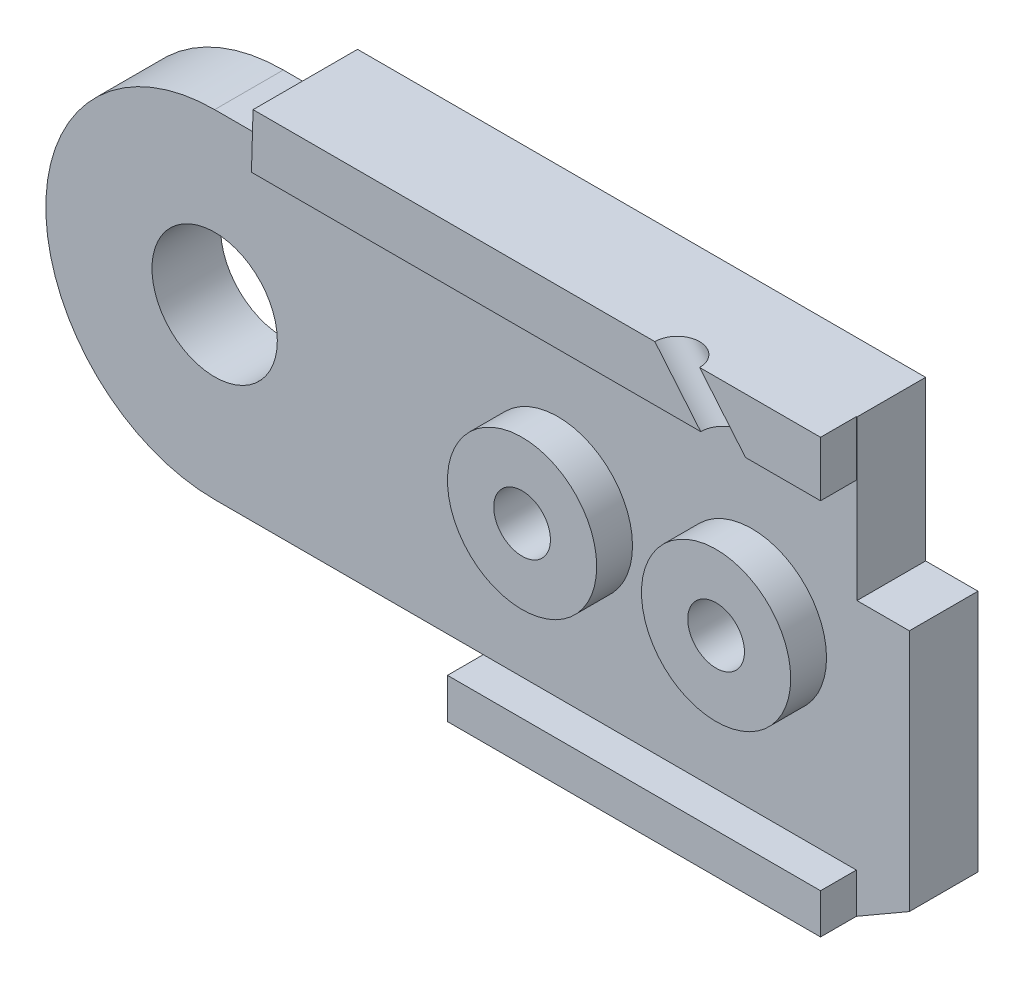
from build123d import *

# Parameters (mm, degrees)
BOSS_EXTRUDE1_DEPTH  = 2
BOSS_EXTRUDE6_DEPTH  = 2.5
CUT_EXTRUDE6_DEPTH   = 2.5
BOSS_EXTRUDE14_DEPTH = 2.3
SKETCH32_R           = 2.1
CUT_EXTRUDE7_DEPTH   = 2.3
SKETCH33_W           = 12.5
SKETCH33_H           = 1.343145751
BOSS_EXTRUDE15_DEPTH = 1.2
SKETCH35_W           = 5.479645997
SKETCH35_H           = 5.327993755
CUT_EXTRUDE8_DEPTH   = 2.4
SKETCH36_W           = 3.7
SKETCH36_H           = 1.827993755
CUT_EXTRUDE9_DEPTH   = 2.4
SKETCH37_R           = 3.9
BOSS_EXTRUDE16_DEPTH = 2.3
CUT_EXTRUDE10_DEPTH  = 5.3
SKETCH43_R           = 2.5
BOSS_EXTRUDE17_DEPTH = 1.2
SKETCH44_R           = 0.95
CUT_EXTRUDE11_DEPTH  = 9
SKETCH45_R           = 2
CUT_EXTRUDE12_DEPTH  = 2.5
SKETCH52_R           = 0.75
CUT_EXTRUDE13_DEPTH  = 10


with BuildPart() as part:
    # Sketch3 → Boss-Extrude1 (new body)
    with BuildSketch(Plane.XY):
        with BuildLine():
            Line((8, 0), (9, -2.5))
            Line((9, -2.5), (9, -7))
            Line((9, -7), (21.5, -7))
            Line((21.5, -7), (25.050252532, -4.949747468))
            ThreePointArc((25.050252532, -4.949747468), (36.467156728, -2.678784027), (30, 7))
            Line((30, 7), (27, 7.5))
            Line((27, 7.5), (5.656854249, 7.5))
            Line((5.656854249, 7.5), (5.656854249, 5.656854249))
            ThreePointArc((5.656854249, 5.656854249), (7.39103626, 3.061467459), (8, 0))
        make_face()
    extrude(amount=BOSS_EXTRUDE1_DEPTH)

    # Sketch22 → Boss-Extrude6 (add)
    with BuildSketch(Plane.XY.offset(2)):
        with BuildLine():
            Line((5.656854249, 5.656854249), (2.486790148, 5.656854249))
            Line((2.486790148, 5.656854249), (2.486790148, 7.5))
            Line((2.486790148, 7.5), (5.656854249, 7.5))
            Line((5.656854249, 7.5), (21.5, 7.5))
            Line((21.5, 7.5), (27, 7.5))
            Line((27, 7.5), (27, 2.172006245))
            Line((27, 2.172006245), (23.275126266, 2.172006245))
            Line((23.275126266, 2.172006245), (23.275126266, -5.974873734))
            Line((23.275126266, -5.974873734), (21.5, -7))
            Line((21.5, -7), (9, -7))
            Line((9, -7), (9, -2.5))
            Line((9, -2.5), (8, 0))
            ThreePointArc((8, 0), (7.39103626, 3.061467459), (5.656854249, 5.656854249))
        make_face()
    extrude(amount=BOSS_EXTRUDE6_DEPTH)

    # Sketch26 → Cut-Extrude6 (cut)
    with BuildSketch(Plane.XY.offset(2)):
        Polygon((18.098080448, 5.3), (2.530052458, 5.3), (2.530052458, 4), (18.098080448, 4), (27, 4), (27, 5.3), align=None)
    extrude(amount=CUT_EXTRUDE6_DEPTH, mode=Mode.SUBTRACT)


with BuildPart() as body_2:
    # Sketch31 → Boss-Extrude14 (new body)
    with BuildSketch(Plane.XY.offset(4.5)):
        with BuildLine():
            Line((2.432688066, 5.656854249), (0, 5.656854249))
            ThreePointArc((0, 5.656854249), (-5.656854249, 0), (0, -5.656854249))
            Line((0, -5.656854249), (9, -5.656854249))
            Line((9, -5.656854249), (9, -7))
            Line((9, -7), (21.5, -7))
            Line((21.5, -7), (23.275126266, -5.974873734))
            Line((23.275126266, -5.974873734), (23.275126266, 2.172006245))
            Line((23.275126266, 2.172006245), (27, 2.172006245))
            Line((27, 2.172006245), (27, 7.5))
            Line((27, 7.5), (2.486790148, 7.5))
            Line((2.486790148, 7.5), (2.432688066, 5.656854249))
        make_face()
    extrude(amount=BOSS_EXTRUDE14_DEPTH)

    # Sketch32 → Cut-Extrude7 (cut)
    with BuildSketch(Plane.XY.offset(6.8)):
        Circle(SKETCH32_R)
    extrude(amount=-CUT_EXTRUDE7_DEPTH, mode=Mode.SUBTRACT)

    # Sketch33 → Boss-Extrude15 (add)
    with BuildSketch(Plane.XY.offset(6.8)):
        with Locations((15.25, -6.328427125)):
            Rectangle(SKETCH33_W, SKETCH33_H)
        Polygon((2.486790148, 7.5), (21.5, 7.5), (21.5, 5.656854249), (2.432688066, 5.656854249), align=None)
    extrude(amount=BOSS_EXTRUDE15_DEPTH)


with BuildPart() as cut_extrude8_tool:
    # Sketch35 → Cut-Extrude8 (new body)
    with BuildSketch(Plane.XY.offset(6.8)):
        with Locations((24.260177002, 4.836003123)):
            Rectangle(SKETCH35_W, SKETCH35_H)
    extrude(amount=-CUT_EXTRUDE8_DEPTH)


with BuildPart() as part_1:
    add(part.part)

    # Cut-Extrude8: cut by cut_extrude8_tool
    add(cut_extrude8_tool.part, mode=Mode.SUBTRACT)

    # Sketch36 → Cut-Extrude9 (cut)
    with BuildSketch(Plane.XY.offset(4.4)):
        with Locations((25.15, 3.086003123)):
            Rectangle(SKETCH36_W, SKETCH36_H)
    extrude(amount=-CUT_EXTRUDE9_DEPTH, mode=Mode.SUBTRACT)

    # Sketch37 → Boss-Extrude16 (add)
    with BuildSketch(Plane.XY.offset(2)):
        with Locations((30, 0)):
            Circle(SKETCH37_R)
    extrude(amount=BOSS_EXTRUDE16_DEPTH)

    # Sketch39 → Cut-Extrude10 (cut, through all)
    with BuildSketch(Plane.XY.offset(4.3)):
        with BuildLine():
            Line((29, 1.732050808), (29, -1.732050808))
            ThreePointArc((29, -1.732050808), (32, 0), (29, 1.732050808))
        make_face()
    extrude(amount=-CUT_EXTRUDE10_DEPTH, mode=Mode.SUBTRACT)


with BuildPart() as body_2_1:
    add(body_2.part)

    # Cut-Extrude8: cut by cut_extrude8_tool
    add(cut_extrude8_tool.part, mode=Mode.SUBTRACT)

    # Sketch43 → Boss-Extrude17 (add)
    with BuildSketch(Plane.XY.offset(6.8)):
        with Locations((11.5, 0)):
            Circle(SKETCH43_R)
        with Locations((18, 0)):
            Circle(SKETCH43_R)
    extrude(amount=BOSS_EXTRUDE17_DEPTH)


with BuildPart() as cut_extrude11_tool:
    # Sketch44 → Cut-Extrude11 (new body, through all)
    with BuildSketch(Plane.XY.offset(8)):
        with Locations((11.5, 0)):
            Circle(SKETCH44_R)
        with Locations((18, 0)):
            Circle(SKETCH44_R)
    extrude(amount=-CUT_EXTRUDE11_DEPTH)


with BuildPart() as part_2:
    add(part_1.part)

    # Cut-Extrude11: cut by cut_extrude11_tool
    add(cut_extrude11_tool.part, mode=Mode.SUBTRACT)

    # Sketch45 → Cut-Extrude12 (cut)
    with BuildSketch(Plane(origin=(0, 0, 0), x_dir=(-1, 0, 0), z_dir=(0, 0, -1))):
        with Locations((-11.5, 0)):
            Circle(SKETCH45_R)
        with Locations((-18, 0)):
            Circle(SKETCH45_R)
    extrude(amount=-CUT_EXTRUDE12_DEPTH, mode=Mode.SUBTRACT)


with BuildPart() as body_2_2:
    add(body_2_1.part)

    # Cut-Extrude11: cut by cut_extrude11_tool
    add(cut_extrude11_tool.part, mode=Mode.SUBTRACT)

    # Sketch52 → Cut-Extrude13 (cut, along a direction that is not the sketch's normal)
    with BuildSketch(Plane.XZ.offset(-5.656854249)):
        with Locations((18.235476819, 8)):
            Circle(SKETCH52_R)
    extrude(amount=-CUT_EXTRUDE13_DEPTH, dir=(0.640410196, -0.76803306, 0), mode=Mode.SUBTRACT)


solid = body_2_2.part
